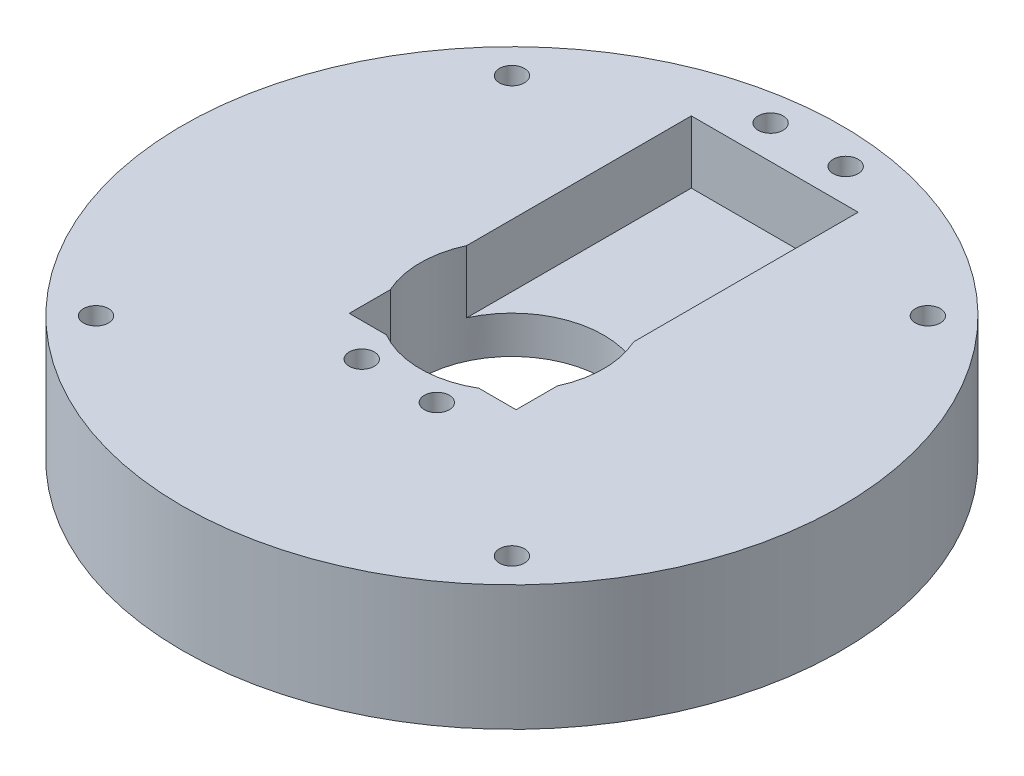
from build123d import *

# Parameters (mm, degrees)
CROQUIS1_R              = 39.5
CROQUIS1_R_2            = 11
CROQUIS1_R_3            = 1.5
SALIENTE_EXTRUIR2_DEPTH = 15
CROQUIS2_R              = 1.5
CROQUIS2_W              = 20
CROQUIS2_H              = 41
CORTAR_EXTRUIR1_DEPTH   = 7.5
CROQUIS2_2_R            = 1.5
CORTAR_EXTRUIR2_DEPTH   = 58.840297371
CROQUIS3_R              = 25
CORTAR_EXTRUIR3_DEPTH   = 3


with BuildPart() as part:
    # Croquis1 → Saliente-Extruir2 (new body)
    with BuildSketch(Plane(origin=(0, 0, 0), x_dir=(1, 0, 0), z_dir=(0, 1, 0))):
        Circle(CROQUIS1_R)
        Circle(CROQUIS1_R_2, mode=Mode.SUBTRACT)
        with Locations((24.925514037, 24.925514037)):
            Circle(CROQUIS1_R_3, mode=Mode.SUBTRACT)
        with Locations((24.925514037, -24.925514037)):
            Circle(CROQUIS1_R_3, mode=Mode.SUBTRACT)
        with Locations((-24.925514037, -24.925514037)):
            Circle(CROQUIS1_R_3, mode=Mode.SUBTRACT)
        with Locations((-24.925514037, 24.925514037)):
            Circle(CROQUIS1_R_3, mode=Mode.SUBTRACT)
    extrude(amount=SALIENTE_EXTRUIR2_DEPTH)

    # Croquis2 → Cortar-Extruir1 (cut)
    with BuildSketch(Plane(origin=(0, 15, 0), x_dir=(1, 0, 0), z_dir=(0, 1, 0))):
        with Locations((-4.5, -13.5)):
            Circle(CROQUIS2_R)
        with Locations((4.5, -13.5)):
            Circle(CROQUIS2_R)
        with Locations((4.5, 35.5)):
            Circle(CROQUIS2_R)
        with Locations((-4.5, 35.5)):
            Circle(CROQUIS2_R)
        with Locations((0, 11)):
            Rectangle(CROQUIS2_W, CROQUIS2_H)
    extrude(amount=-CORTAR_EXTRUIR1_DEPTH, mode=Mode.SUBTRACT)

    # Croquis2_2 → Cortar-Extruir2 (cut, through all)
    with BuildSketch(Plane(origin=(0, 15, 0), x_dir=(1, 0, 0), z_dir=(0, 1, 0))):
        with Locations((-4.5, -13.5)):
            Circle(CROQUIS2_2_R)
        with Locations((4.5, -13.5)):
            Circle(CROQUIS2_2_R)
        with Locations((4.5, 35.5)):
            Circle(CROQUIS2_2_R)
        with Locations((-4.5, 35.5)):
            Circle(CROQUIS2_2_R)
    extrude(amount=-CORTAR_EXTRUIR2_DEPTH, mode=Mode.SUBTRACT)

    # Croquis3 → Cortar-Extruir3 (cut)
    with BuildSketch(Plane.XZ):
        Circle(CROQUIS3_R)
    extrude(amount=-CORTAR_EXTRUIR3_DEPTH, mode=Mode.SUBTRACT)


solid = part.part
